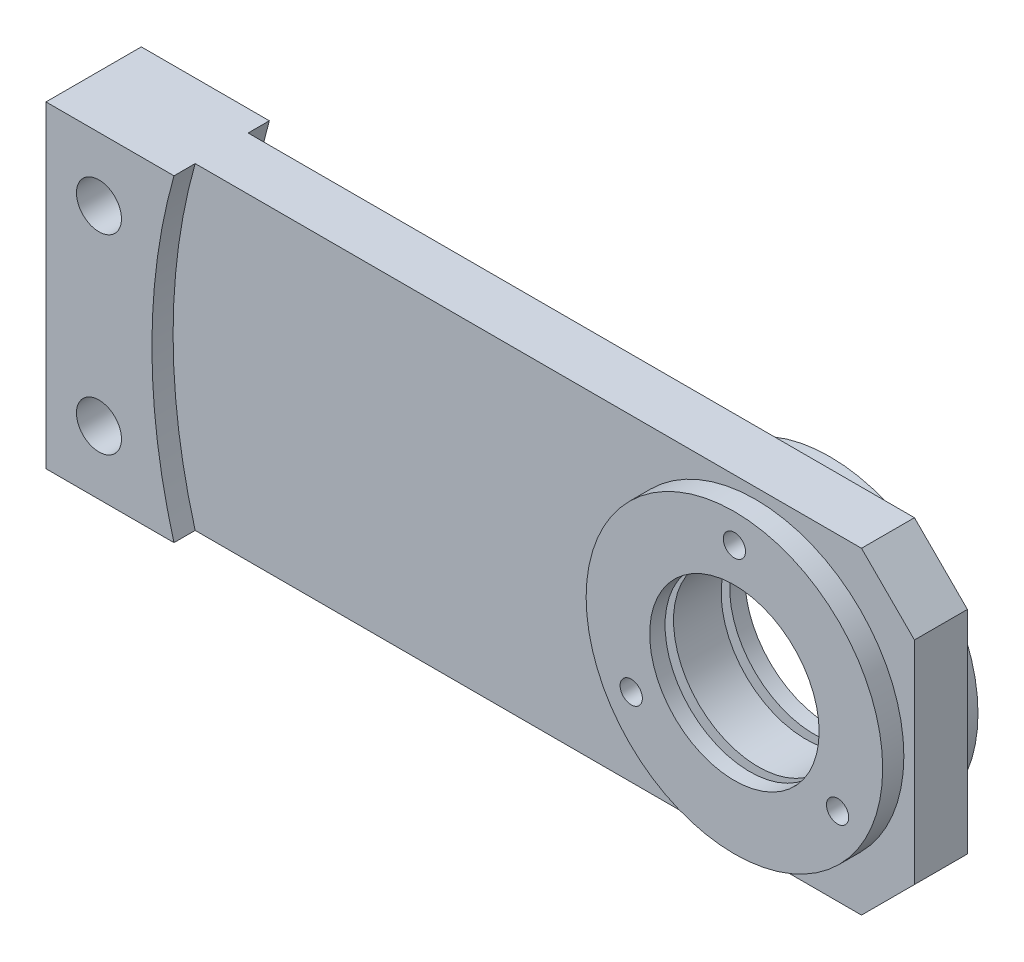
from build123d import *

# Parameters (mm, degrees)
SKETCH1_W           = 160
SKETCH1_H           = 60
SKETCH1_R           = 4.25
SKETCH1_R_2         = 16
BOSS_EXTRUDE1_DEPTH = 9
CIRPATTERN2_COUNT   = 3
CHAMFER1_SIZE       = 10
SKETCH5_R           = 18.5
SKETCH5_R_2         = 16
CUT_EXTRUDE2_DEPTH  = 1.6
SKETCH4_R           = 28
CUT_EXTRUDE1_DEPTH  = 4


with BuildPart() as part:
    # Sketch1 → Boss-Extrude1 (new body, symmetric)
    with BuildSketch(Plane.XY):
        Rectangle(SKETCH1_W, SKETCH1_H)
        with Locations((-70, 18)):
            Circle(SKETCH1_R, mode=Mode.SUBTRACT)
        with Locations((-70, -18)):
            Circle(SKETCH1_R, mode=Mode.SUBTRACT)
        with Locations((50, 0)):
            Circle(SKETCH1_R_2, mode=Mode.SUBTRACT)
    extrude(amount=BOSS_EXTRUDE1_DEPTH, both=True)

    # Sketch3 → M5 Tapped Hole1 (revolve, cut)
    with BuildSketch(Plane(origin=(50, 22.5, 9), x_dir=(0, -1, 0), z_dir=(1, 0, 0))):
        Polygon((0, 0), (0, 11.2618073), (2.1, 10), (2.1, 0), align=None)
    m5_tapped_hole1 = revolve(axis=Axis((50, 22.5, 15.35), (0, 0, -1)), mode=Mode.SUBTRACT)

    # CirPattern2: M5 Tapped Hole1 ×3 about axis
    cirpattern2_axis = Axis((50, 0, 0), (0, 0, 1))
    for i in range(1, CIRPATTERN2_COUNT):
        add(m5_tapped_hole1.rotate(cirpattern2_axis, i * 360 / CIRPATTERN2_COUNT), mode=Mode.SUBTRACT)

    # Chamfer1
    chamfer1_edges = [part.edges().sort_by_distance(p)[0] for p in [
        (80, 30, 0),
        (80, -30, 0),
    ]]
    chamfer(chamfer1_edges, length=CHAMFER1_SIZE)

    # Sketch5 → Cut-Extrude2 (cut)
    with BuildSketch(Plane.XY.offset(4.5)):
        with Locations((50, 0)):
            Circle(SKETCH5_R)
        with Locations((50, 0)):
            Circle(SKETCH5_R_2, mode=Mode.SUBTRACT)
    cut_extrude2 = extrude(amount=CUT_EXTRUDE2_DEPTH, mode=Mode.SUBTRACT)

    # Mirror2: Cut-Extrude2 across plane
    add(cut_extrude2.mirror(Plane.XY), mode=Mode.SUBTRACT)

    # Sketch4 → Cut-Extrude1 (cut)
    with BuildSketch(Plane.XY.offset(9)):
        with BuildLine():
            ThreePointArc((-55.830052443, 30), (-60, 0), (-55.830052443, -30))
            Line((-55.830052443, -30), (70, -30))
            Line((70, -30), (80, -20))
            Line((80, -20), (80, 20))
            Line((80, 20), (70, 30))
            Line((70, 30), (-55.830052443, 30))
        make_face()
        with Locations((50, 0)):
            Circle(SKETCH4_R, mode=Mode.SUBTRACT)
    cut_extrude1 = extrude(amount=-CUT_EXTRUDE1_DEPTH, mode=Mode.SUBTRACT)

    # Mirror1: Cut-Extrude1 across plane
    add(cut_extrude1.mirror(Plane.XY), mode=Mode.SUBTRACT)


solid = part.part
